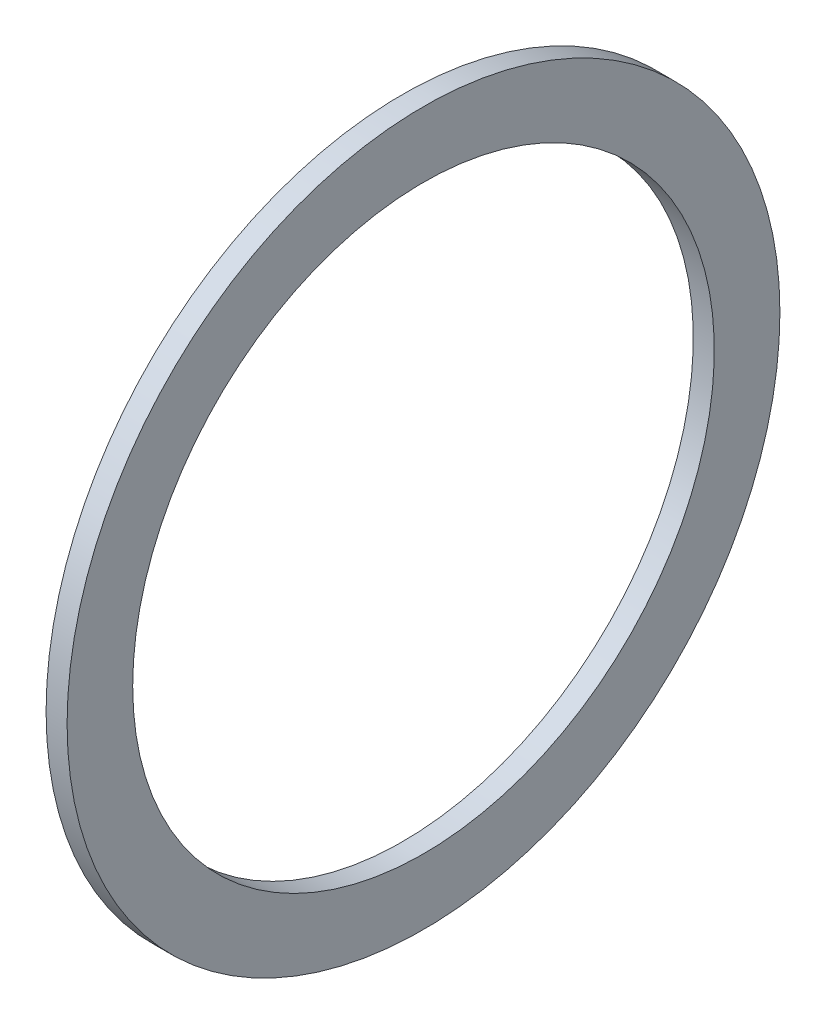
from build123d import *

# Parameters (mm, degrees)
SKETCH3_W = 3.2385
SKETCH3_H = 10.111500097


with BuildPart() as part:
    # Sketch3 → Revolve1 (revolve)
    with BuildSketch(Plane.XY):
        with Locations((6.604050038, 49.880749933)):
            Rectangle(SKETCH3_W, SKETCH3_H)
    revolve(axis=Axis((0, 0, 0), (1, 0, 0)))


solid = part.part
